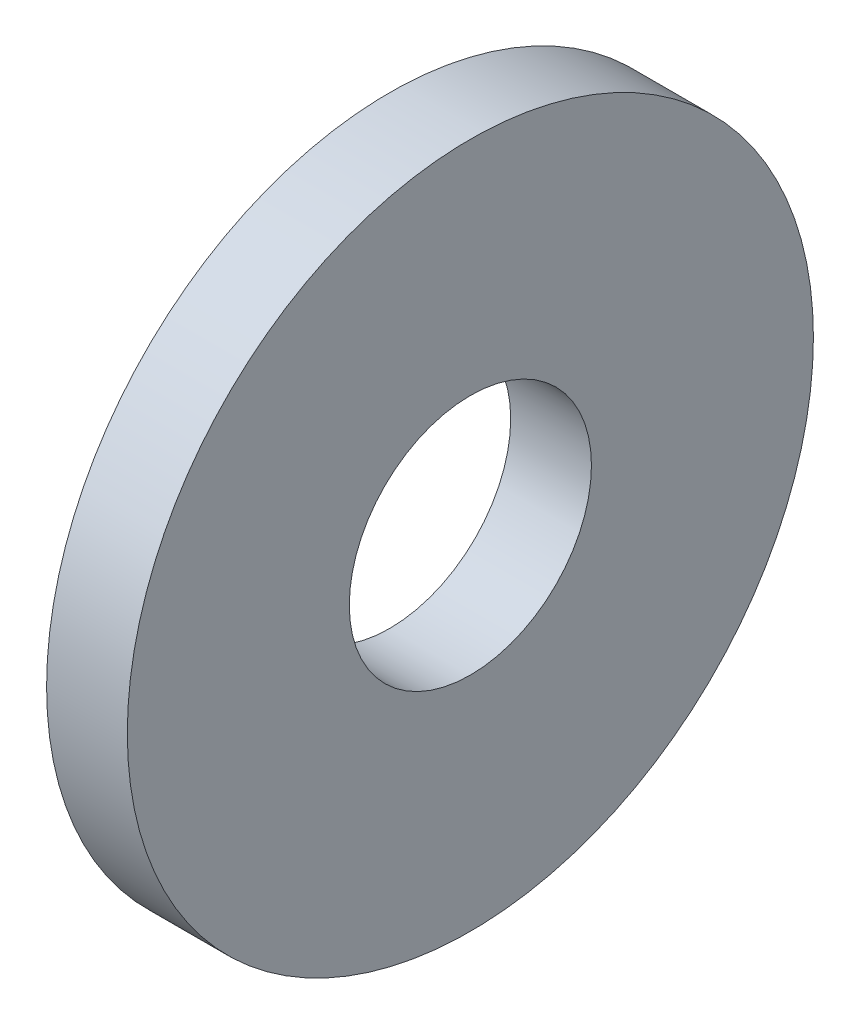
from build123d import *

# Parameters (mm, degrees)
SKETCH1_R               = 17
BOSS_EXTRUDE1_DEPTH     = 2
SKETCH2_R               = 6
CUT_EXTRUDE1_DEPTH      = 3
CUT_EXTRUDE1_DEPTH_BACK = 3


with BuildPart() as part:
    # Sketch1 → Boss-Extrude1 (new body, symmetric)
    with BuildSketch(Plane(origin=(0, 0, 0), x_dir=(0, 0, -1), z_dir=(1, 0, 0))):
        Circle(SKETCH1_R)
    extrude(amount=BOSS_EXTRUDE1_DEPTH, both=True)

    # Sketch2 → Cut-Extrude1 (cut, two sides)
    with BuildSketch(Plane(origin=(0, 0, 0), x_dir=(0, 0, -1), z_dir=(1, 0, 0))) as cut_extrude1_sk:
        Circle(SKETCH2_R)
    extrude(amount=CUT_EXTRUDE1_DEPTH, mode=Mode.SUBTRACT)
    extrude(cut_extrude1_sk.sketch, amount=-CUT_EXTRUDE1_DEPTH_BACK, mode=Mode.SUBTRACT)


solid = part.part
